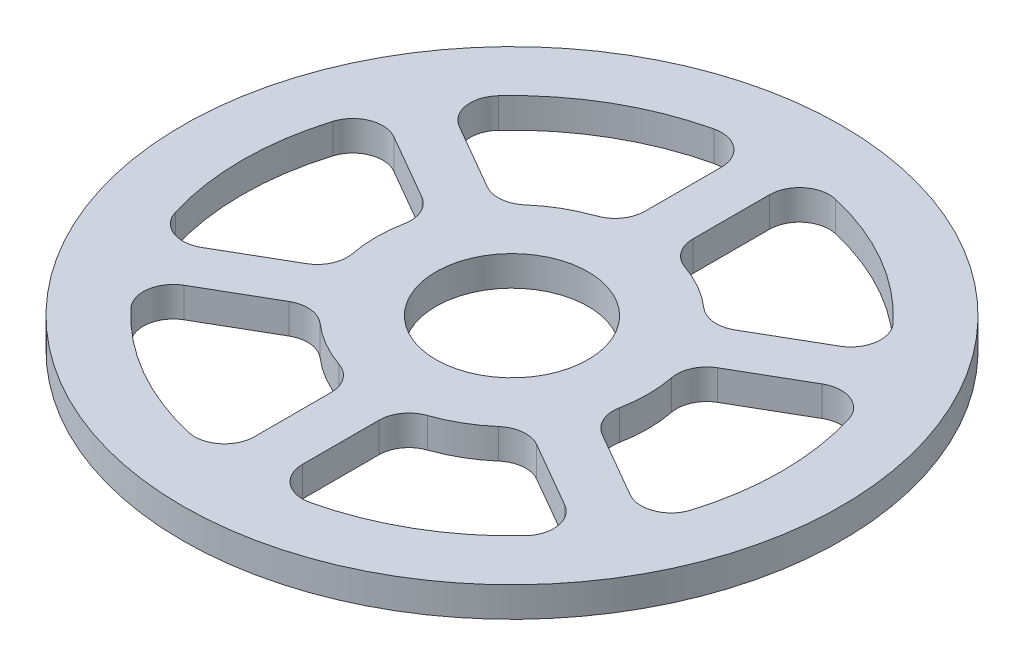
from build123d import *

# Parameters (mm, degrees)
SKETCH1_R           = 55
BOSS_EXTRUDE1_DEPTH = 5
SKETCH2_R           = 1.5
CUT_EXTRUDE1_DEPTH  = 2.5
SKETCH5_R           = 12.7
CUT_EXTRUDE4_DEPTH  = 6
CUT_EXTRUDE5_DEPTH  = 6
FILLET1_R           = 5
FILLET2_R           = 5


with BuildPart() as part:
    # Sketch1 → Boss-Extrude1 (new body)
    with BuildSketch(Plane(origin=(0, 0, 0), x_dir=(1, 0, 0), z_dir=(0, 1, 0))):
        Circle(SKETCH1_R)
    extrude(amount=BOSS_EXTRUDE1_DEPTH)

    # Sketch2 → Cut-Extrude1 (cut)
    with BuildSketch(Plane(origin=(0, 0, 0), x_dir=(1, 0, 0), z_dir=(0, 1, 0))):
        with Locations((0, 51)):
            Circle(SKETCH2_R)
        with Locations((44.167295593, 25.5)):
            Circle(SKETCH2_R)
        with Locations((44.167295593, -25.5)):
            Circle(SKETCH2_R)
        with Locations((0, -51)):
            Circle(SKETCH2_R)
        with Locations((-44.167295593, -25.5)):
            Circle(SKETCH2_R)
        with Locations((-44.167295593, 25.5)):
            Circle(SKETCH2_R)
    extrude(amount=CUT_EXTRUDE1_DEPTH, mode=Mode.SUBTRACT)

    # Sketch5 → Cut-Extrude4 (cut, through all)
    with BuildSketch(Plane(origin=(0, 5, 0), x_dir=(1, 0, 0), z_dir=(0, 1, 0))):
        Circle(SKETCH5_R)
    extrude(amount=-CUT_EXTRUDE4_DEPTH, mode=Mode.SUBTRACT)

    # Sketch7 → Cut-Extrude5 (cut, through all)
    with BuildSketch(Plane(origin=(0, 5, 0), x_dir=(1, 0, 0), z_dir=(0, 1, 0))):
        with BuildLine():
            Line((-21.351162756, 7.708297411), (-40.816877772, 18.946833216))
            ThreePointArc((-40.816877772, 18.946833216), (-45, 0), (-40.816877772, -18.946833216))
            Line((-40.816877772, -18.946833216), (-21.351162756, -7.708297411))
            ThreePointArc((-21.351162756, -7.708297411), (-22.7, 0), (-21.351162756, 7.708297411))
        make_face()
        with BuildLine():
            Line((-17.351162756, -14.636500641), (-36.816877772, -25.875036446))
            ThreePointArc((-36.816877772, -25.875036446), (-22.5, -38.97114317), (-4, -44.821869662))
            Line((-4, -44.821869662), (-4, -22.344798052))
            ThreePointArc((-4, -22.344798052), (-11.35, -19.658776666), (-17.351162756, -14.636500641))
        make_face()
        with BuildLine():
            ThreePointArc((4, -44.821869662), (22.5, -38.97114317), (36.816877772, -25.875036446))
            Line((36.816877772, -25.875036446), (17.351162756, -14.636500641))
            ThreePointArc((17.351162756, -14.636500641), (11.35, -19.658776666), (4, -22.344798052))
            Line((4, -22.344798052), (4, -44.821869662))
        make_face()
        with BuildLine():
            ThreePointArc((45, 0), (43.941776818, 9.701559159), (40.816877772, 18.946833216))
            Line((40.816877772, 18.946833216), (21.351162756, 7.708297411))
            ThreePointArc((21.351162756, 7.708297411), (22.360248149, 3.912710406), (22.7, 0))
            ThreePointArc((22.7, 0), (22.360248149, -3.912710406), (21.351162756, -7.708297411))
            Line((21.351162756, -7.708297411), (40.816877772, -18.946833216))
            ThreePointArc((40.816877772, -18.946833216), (43.941776818, -9.701559159), (45, 0))
        make_face()
        with BuildLine():
            ThreePointArc((36.816877772, 25.875036446), (22.5, 38.97114317), (4, 44.821869662))
            Line((4, 44.821869662), (4, 22.344798052))
            ThreePointArc((4, 22.344798052), (11.35, 19.658776666), (17.351162756, 14.636500641))
            Line((17.351162756, 14.636500641), (36.816877772, 25.875036446))
        make_face()
        with BuildLine():
            Line((-4, 22.344798052), (-4, 44.821869662))
            ThreePointArc((-4, 44.821869662), (-22.5, 38.97114317), (-36.816877772, 25.875036446))
            Line((-36.816877772, 25.875036446), (-17.351162756, 14.636500641))
            ThreePointArc((-17.351162756, 14.636500641), (-11.35, 19.658776666), (-4, 22.344798052))
        make_face()
    extrude(amount=-CUT_EXTRUDE5_DEPTH, mode=Mode.SUBTRACT)

    # Fillet1
    fillet1_edges = [part.edges().sort_by_distance(p)[0] for p in [
        (-40.816877772, 2.5, -18.946833216),
        (-21.351162756, 2.5, -7.708297411),
        (-21.351162756, 2.5, 7.708297411),
        (-40.816877772, 2.5, 18.946833216),
    ]]
    fillet(fillet1_edges, radius=FILLET1_R)

    # Fillet2
    fillet2_edges = [part.edges().sort_by_distance(p)[0] for p in [
        (40.816877772, 2.5, 18.946833216),
        (21.351162756, 2.5, 7.708297411),
        (21.351162756, 2.5, -7.708297411),
        (40.816877772, 2.5, -18.946833216),
        (36.816877772, 2.5, -25.875036446),
        (17.351162756, 2.5, -14.636500641),
        (4, 2.5, -22.344798052),
        (4, 2.5, -44.821869662),
        (4, 2.5, 44.821869662),
        (4, 2.5, 22.344798052),
        (17.351162756, 2.5, 14.636500641),
        (36.816877772, 2.5, 25.875036446),
        (-36.816877772, 2.5, 25.875036446),
        (-17.351162756, 2.5, 14.636500641),
        (-4, 2.5, 22.344798052),
        (-4, 2.5, 44.821869662),
        (-4, 2.5, -44.821869662),
        (-4, 2.5, -22.344798052),
        (-17.351162756, 2.5, -14.636500641),
        (-36.816877772, 2.5, -25.875036446),
    ]]
    fillet(fillet2_edges, radius=FILLET2_R)


solid = part.part
